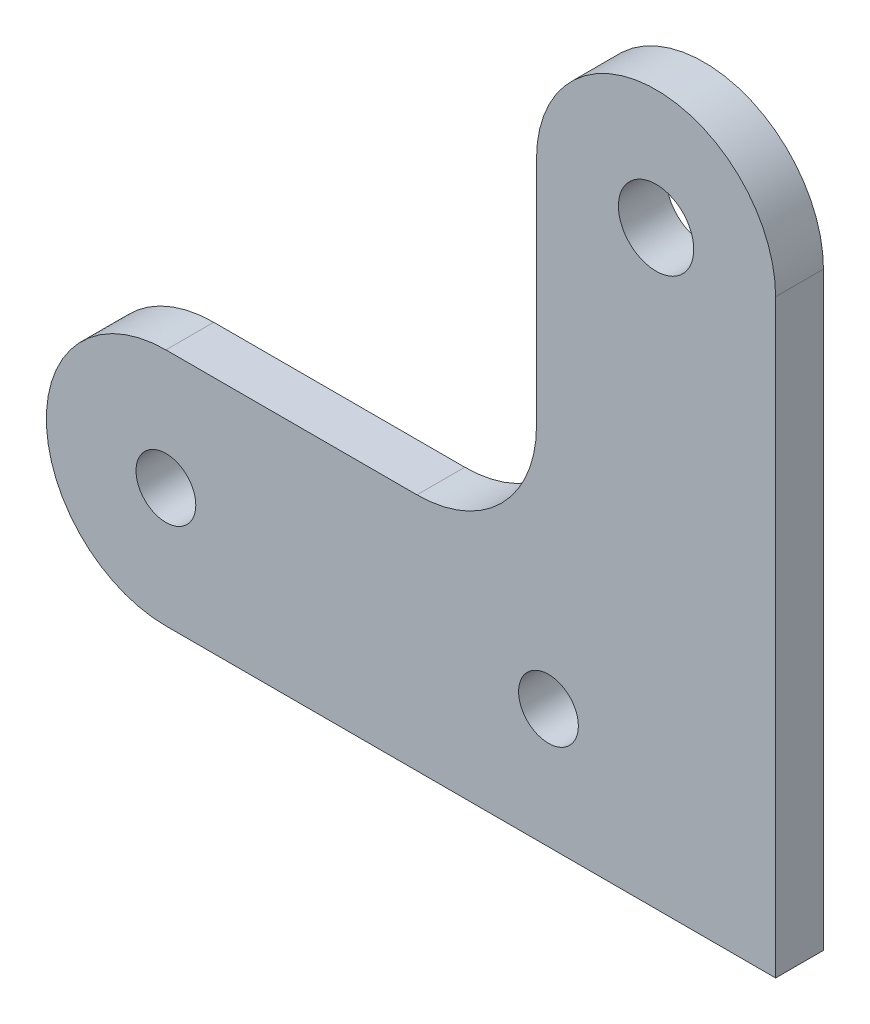
from build123d import *

# Parameters (mm, degrees)
SKETCH_1_R      = 2.5
SKETCH_1_R_2    = 3.15
EXTRUDE_1_DEPTH = 4


with BuildPart() as part:
    # 草图1 → 凸台-拉伸1 (new body)
    with BuildSketch(Plane.XY):
        with BuildLine():
            ThreePointArc((-11, 10), (-3.928932188, 12.928932188), (-1, 20))
            Line((-1, 20), (-1, 39.35))
            ThreePointArc((-1, 39.35), (9, 49.35), (19, 39.35))
            Line((19, 39.35), (19, -10))
            Line((19, -10), (-32, -10))
            ThreePointArc((-32, -10), (-42, 0), (-32, 10))
            Line((-32, 10), (-11, 10))
        make_face()
        with Locations((-32, 0)):
            Circle(SKETCH_1_R, mode=Mode.SUBTRACT)
        with Locations((9, 39.35)):
            Circle(SKETCH_1_R_2, mode=Mode.SUBTRACT)
        Circle(SKETCH_1_R, mode=Mode.SUBTRACT)
    extrude(amount=EXTRUDE_1_DEPTH)


solid = part.part
